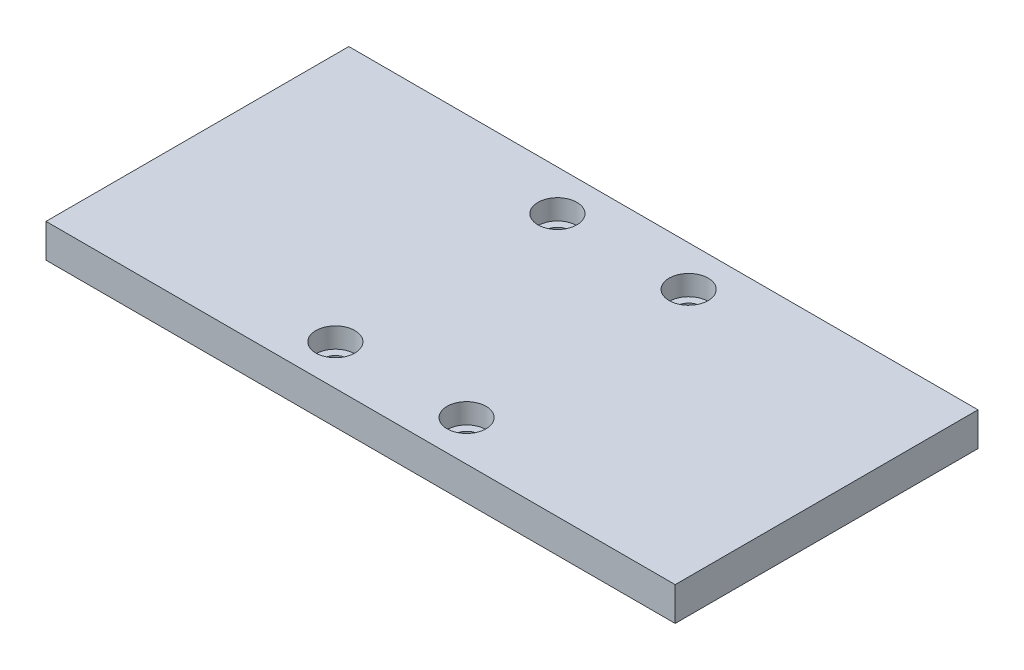
from build123d import *

# Parameters (mm, degrees)
SKETCH1_W               = 93.5
SKETCH1_H               = 45
BOSS_EXTRUDE1_DEPTH     = 5
SKETCH2_R               = 1.75
CUT_EXTRUDE1_DEPTH      = 1
CUT_EXTRUDE1_DEPTH_BACK = 6
SKETCH3_R               = 2.9
CUT_EXTRUDE2_DEPTH      = 1
CUT_EXTRUDE2_DEPTH_BACK = 3


with BuildPart() as part:
    # Sketch1 → Boss-Extrude1 (new body)
    with BuildSketch(Plane(origin=(0, 0, 0), x_dir=(1, 0, 0), z_dir=(0, 1, 0))):
        Rectangle(SKETCH1_W, SKETCH1_H)
    extrude(amount=BOSS_EXTRUDE1_DEPTH)

    # Sketch2 → Cut-Extrude1 (cut, two sides)
    with BuildSketch(Plane(origin=(0, 5, 0), x_dir=(1, 0, 0), z_dir=(0, 1, 0))) as cut_extrude1_sk:
        with Locations((-9.75, -16.5)):
            Circle(SKETCH2_R)
        with Locations((-9.75, 16.5)):
            Circle(SKETCH2_R)
        with Locations((9.75, -16.5)):
            Circle(SKETCH2_R)
        with Locations((9.75, 16.5)):
            Circle(SKETCH2_R)
    extrude(amount=CUT_EXTRUDE1_DEPTH, mode=Mode.SUBTRACT)
    extrude(cut_extrude1_sk.sketch, amount=-CUT_EXTRUDE1_DEPTH_BACK, mode=Mode.SUBTRACT)

    # Sketch3 → Cut-Extrude2 (cut, two sides)
    with BuildSketch(Plane(origin=(0, 5, 0), x_dir=(1, 0, 0), z_dir=(0, 1, 0))) as cut_extrude2_sk:
        with Locations((-9.75, 16.5)):
            Circle(SKETCH3_R)
        with Locations((9.75, 16.5)):
            Circle(SKETCH3_R)
        with Locations((9.75, -16.5)):
            Circle(SKETCH3_R)
        with Locations((-9.75, -16.5)):
            Circle(SKETCH3_R)
    extrude(amount=CUT_EXTRUDE2_DEPTH, mode=Mode.SUBTRACT)
    extrude(cut_extrude2_sk.sketch, amount=-CUT_EXTRUDE2_DEPTH_BACK, mode=Mode.SUBTRACT)


solid = part.part
